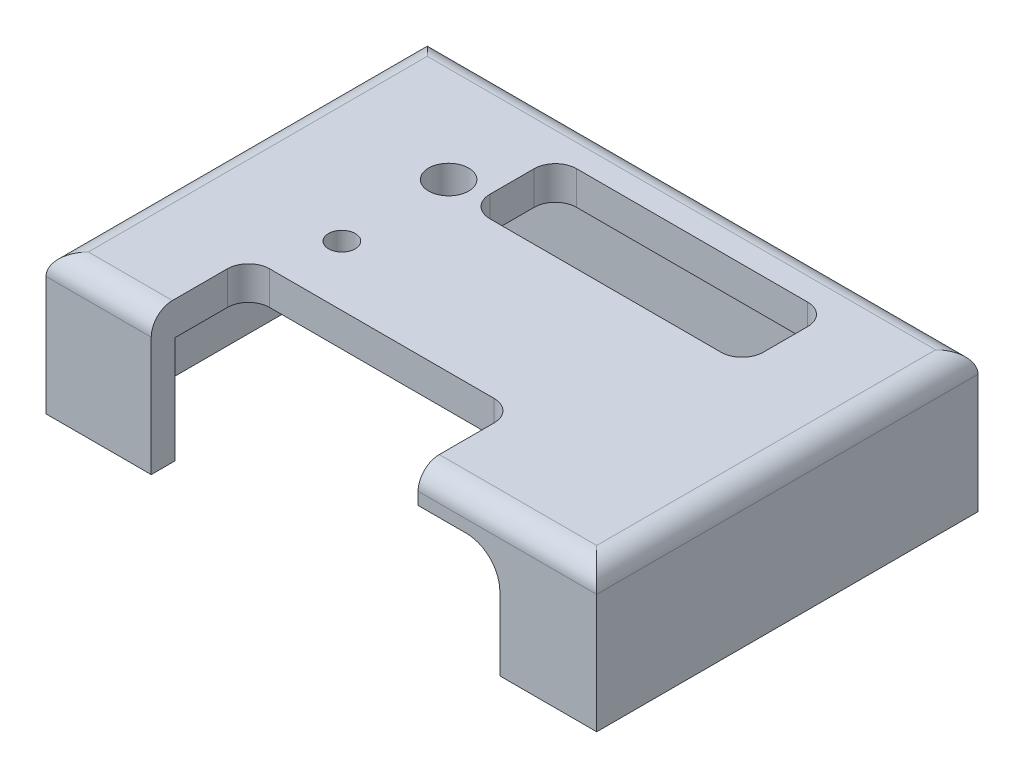
from build123d import *

# Parameters (mm, degrees)
SKETCH1_W                 = 82.55
SKETCH1_H                 = 57.15
BOSS_EXTRUDE1_DEPTH       = 21.018
CUT_EXTRUDE1_DEPTH        = 16
F_8_32_TAPPED_HOLE1_D     = 3.4544
F_8_32_TAPPED_HOLE1_DEPTH = 10.708
F_8_32_TAPPED_HOLE1_TIP   = 1.037806461
FILLET1_R                 = 3.175
SKETCH6_R                 = 3
SKETCH6_R_2               = 2
CUT_EXTRUDE2_DEPTH        = 22.018
CUT_EXTRUDE3_REACH        = 59.15


with BuildPart() as part:
    # Sketch1 → Boss-Extrude1 (new body)
    with BuildSketch(Plane(origin=(0, 0, 0), x_dir=(1, 0, 0), z_dir=(0, 1, 0))):
        Rectangle(SKETCH1_W, SKETCH1_H)
    extrude(amount=BOSS_EXTRUDE1_DEPTH)

    # Sketch2 → Cut-Extrude1 (cut)
    with BuildSketch(Plane(origin=(0, 0, 0), x_dir=(1, 0, 0), z_dir=(0, 1, 0))):
        with BuildLine():
            Line((30.15, -25), (-30.15, -25))
            ThreePointArc((-30.15, -25), (-34.640128061, -23.140128061), (-36.5, -18.65))
            Line((-36.5, -18.65), (-36.5, 18.65))
            ThreePointArc((-36.5, 18.65), (-34.640128061, 23.140128061), (-30.15, 25))
            Line((-30.15, 25), (30.15, 25))
            ThreePointArc((30.15, 25), (34.640128061, 23.140128061), (36.5, 18.65))
            Line((36.5, 18.65), (36.5, -18.65))
            ThreePointArc((36.5, -18.65), (34.640128061, -23.140128061), (30.15, -25))
        make_face()
    extrude(amount=CUT_EXTRUDE1_DEPTH, mode=Mode.SUBTRACT)

    # #8-32 Tapped Hole1
    with Locations(Plane(origin=(0, 0, 0), x_dir=(-1, 0, 0), z_dir=(0, -1, 0))):
        with Locations((37.275, -24.575), (37.275, 24.575), (-37.275, -24.575), (-37.275, 24.575)):
            Hole(F_8_32_TAPPED_HOLE1_D / 2, depth=F_8_32_TAPPED_HOLE1_DEPTH)
            with Locations((0, 0, -(F_8_32_TAPPED_HOLE1_DEPTH + F_8_32_TAPPED_HOLE1_TIP / 2))):  # 118° drill point
                Cone(0, F_8_32_TAPPED_HOLE1_D / 2, F_8_32_TAPPED_HOLE1_TIP, mode=Mode.SUBTRACT)

    # Fillet1
    fillet1_edges = [part.edges().sort_by_distance(p)[0] for p in [
        (41.275, 21.018, 0),
        (0, 21.018, -28.575),
        (-41.275, 21.018, 0),
        (0, 21.018, 28.575),
    ]]
    fillet(fillet1_edges, radius=FILLET1_R)

    # Sketch6 → Cut-Extrude2 (cut, through all)
    with BuildSketch(Plane(origin=(0, 21.018, 0), x_dir=(1, 0, 0), z_dir=(0, 1, 0))):
        with Locations((-20.5, 11)):
            Circle(SKETCH6_R)
        with Locations((-20.5, -5)):
            Circle(SKETCH6_R_2)
        with BuildLine():
            Line((-12.325, 9), (22.325, 9))
            ThreePointArc((22.325, 9), (24.57006403, 9.92993597), (25.5, 12.175))
            Line((25.5, 12.175), (25.5, 18.825))
            ThreePointArc((25.5, 18.825), (24.57006403, 21.07006403), (22.325, 22))
            Line((22.325, 22), (-12.325, 22))
            ThreePointArc((-12.325, 22), (-14.57006403, 21.07006403), (-15.5, 18.825))
            Line((-15.5, 18.825), (-15.5, 12.175))
            ThreePointArc((-15.5, 12.175), (-14.57006403, 9.92993597), (-12.325, 9))
        make_face()
        with BuildLine():
            Line((-25.5, -28.575), (14.5, -28.575))
            Line((14.5, -28.575), (14.5, -17.175))
            ThreePointArc((14.5, -17.175), (13.57006403, -14.92993597), (11.325, -14))
            Line((11.325, -14), (-22.325, -14))
            ThreePointArc((-22.325, -14), (-24.57006403, -14.92993597), (-25.5, -17.175))
            Line((-25.5, -17.175), (-25.5, -28.575))
        make_face()
    extrude(amount=-CUT_EXTRUDE2_DEPTH, mode=Mode.SUBTRACT)

    # Sketch7 → Cut-Extrude3 (cut, up to next)
    with BuildSketch(Plane.XY.offset(28.575), mode=Mode.PRIVATE) as cut_extrude3_sk1:
        with BuildLine():
            Line((21.75, 16), (14.5, 16))
            Line((14.5, 16), (14.5, 0))
            Line((14.5, 0), (26.75, 0))
            Line((26.75, 0), (26.75, 11))
            ThreePointArc((26.75, 11), (25.285533906, 14.535533906), (21.75, 16))
        make_face()
    cut_extrude3_tool1 = extrude(cut_extrude3_sk1.sketch, amount=-CUT_EXTRUDE3_REACH, mode=Mode.PRIVATE) & part.part
    add(cut_extrude3_tool1.solids().sort_by_distance((20.484055, 7.806287, 28.575))[0], mode=Mode.SUBTRACT)


solid = part.part
